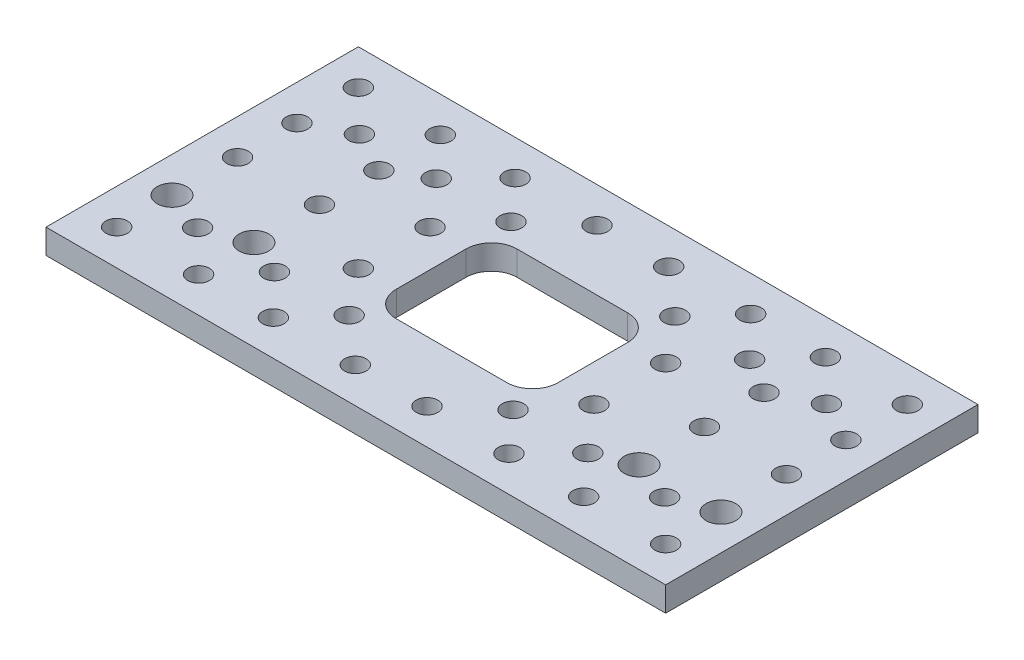
from build123d import *

# Parameters (mm, degrees)
SKETCH1_W           = 153.67
SKETCH1_H           = 77.47
SKETCH1_R           = 2.667
SKETCH1_R_2         = 3.683
BOSS_EXTRUDE1_DEPTH = 6.096


with BuildPart() as part:
    # Sketch1 → Boss-Extrude1 (new body)
    with BuildSketch(Plane(origin=(0, 0, 0), x_dir=(1, 0, 0), z_dir=(0, 1, 0))):
        Rectangle(SKETCH1_W, SKETCH1_H)
        with Locations((-68.072, 29.972)):
            Circle(SKETCH1_R, mode=Mode.SUBTRACT)
        with Locations((-68.072, 14.732)):
            Circle(SKETCH1_R, mode=Mode.SUBTRACT)
        with Locations((-68.072, 0)):
            Circle(SKETCH1_R, mode=Mode.SUBTRACT)
        with Locations((-68.072, -29.972)):
            Circle(SKETCH1_R, mode=Mode.SUBTRACT)
        with Locations((-68.072, -16.256)):
            Circle(SKETCH1_R_2, mode=Mode.SUBTRACT)
        with Locations((-47.752, -29.972)):
            Circle(SKETCH1_R, mode=Mode.SUBTRACT)
        with Locations((-47.752, -16.256)):
            Circle(SKETCH1_R_2, mode=Mode.SUBTRACT)
        with Locations((-47.752, 0)):
            Circle(SKETCH1_R, mode=Mode.SUBTRACT)
        with Locations((-47.752, 14.732)):
            Circle(SKETCH1_R, mode=Mode.SUBTRACT)
        with Locations((-47.752, 29.972)):
            Circle(SKETCH1_R, mode=Mode.SUBTRACT)
        with Locations((-29.21, 29.972)):
            Circle(SKETCH1_R, mode=Mode.SUBTRACT)
        with Locations((-8.89, 29.972)):
            Circle(SKETCH1_R, mode=Mode.SUBTRACT)
        with Locations((-29.21, 8.89)):
            Circle(SKETCH1_R, mode=Mode.SUBTRACT)
        with Locations((-29.21, -8.89)):
            Circle(SKETCH1_R, mode=Mode.SUBTRACT)
        with Locations((-8.89, -29.972)):
            Circle(SKETCH1_R, mode=Mode.SUBTRACT)
        with Locations((-29.21, -29.972)):
            Circle(SKETCH1_R, mode=Mode.SUBTRACT)
        with Locations((-57.912, 20.066)):
            Circle(SKETCH1_R, mode=Mode.SUBTRACT)
        with Locations((-57.912, -20.066)):
            Circle(SKETCH1_R, mode=Mode.SUBTRACT)
        with Locations((-20.32, 20.066)):
            Circle(SKETCH1_R, mode=Mode.SUBTRACT)
        with Locations((-20.32, -20.066)):
            Circle(SKETCH1_R, mode=Mode.SUBTRACT)
        with Locations((-38.862, 20.066)):
            Circle(SKETCH1_R, mode=Mode.SUBTRACT)
        with Locations((-38.862, -20.066)):
            Circle(SKETCH1_R, mode=Mode.SUBTRACT)
        with Locations((20.32, -20.066)):
            Circle(SKETCH1_R, mode=Mode.SUBTRACT)
        with Locations((8.89, -29.972)):
            Circle(SKETCH1_R, mode=Mode.SUBTRACT)
        with Locations((29.21, -29.972)):
            Circle(SKETCH1_R, mode=Mode.SUBTRACT)
        with Locations((38.862, -20.066)):
            Circle(SKETCH1_R, mode=Mode.SUBTRACT)
        with Locations((47.752, -29.972)):
            Circle(SKETCH1_R, mode=Mode.SUBTRACT)
        with Locations((68.072, -29.972)):
            Circle(SKETCH1_R, mode=Mode.SUBTRACT)
        with Locations((68.072, 0)):
            Circle(SKETCH1_R, mode=Mode.SUBTRACT)
        with Locations((68.072, -16.256)):
            Circle(SKETCH1_R_2, mode=Mode.SUBTRACT)
        with Locations((57.912, -20.066)):
            Circle(SKETCH1_R, mode=Mode.SUBTRACT)
        with Locations((47.752, -16.256)):
            Circle(SKETCH1_R_2, mode=Mode.SUBTRACT)
        with Locations((29.21, -8.89)):
            Circle(SKETCH1_R, mode=Mode.SUBTRACT)
        with Locations((29.21, 8.89)):
            Circle(SKETCH1_R, mode=Mode.SUBTRACT)
        with Locations((57.912, 20.066)):
            Circle(SKETCH1_R, mode=Mode.SUBTRACT)
        with Locations((68.072, 14.732)):
            Circle(SKETCH1_R, mode=Mode.SUBTRACT)
        with Locations((68.072, 29.972)):
            Circle(SKETCH1_R, mode=Mode.SUBTRACT)
        with Locations((47.752, 14.732)):
            Circle(SKETCH1_R, mode=Mode.SUBTRACT)
        with Locations((47.752, 0)):
            Circle(SKETCH1_R, mode=Mode.SUBTRACT)
        with Locations((38.862, 20.066)):
            Circle(SKETCH1_R, mode=Mode.SUBTRACT)
        with Locations((20.32, 20.066)):
            Circle(SKETCH1_R, mode=Mode.SUBTRACT)
        with Locations((8.89, 29.972)):
            Circle(SKETCH1_R, mode=Mode.SUBTRACT)
        with Locations((29.21, 29.972)):
            Circle(SKETCH1_R, mode=Mode.SUBTRACT)
        with Locations((47.752, 29.972)):
            Circle(SKETCH1_R, mode=Mode.SUBTRACT)
        with BuildLine():
            Line((13.716, 14.986), (-13.716, 14.986))
            ThreePointArc((-13.716, 14.986), (-18.206128061, 13.126128061), (-20.066, 8.636))
            Line((-20.066, 8.636), (-20.066, -8.636))
            ThreePointArc((-20.066, -8.636), (-18.206128061, -13.126128061), (-13.716, -14.986))
            Line((-13.716, -14.986), (13.716, -14.986))
            ThreePointArc((13.716, -14.986), (18.206128061, -13.126128061), (20.066, -8.636))
            Line((20.066, -8.636), (20.066, 8.636))
            ThreePointArc((20.066, 8.636), (18.206128061, 13.126128061), (13.716, 14.986))
        make_face(mode=Mode.SUBTRACT)
    extrude(amount=BOSS_EXTRUDE1_DEPTH)


solid = part.part
